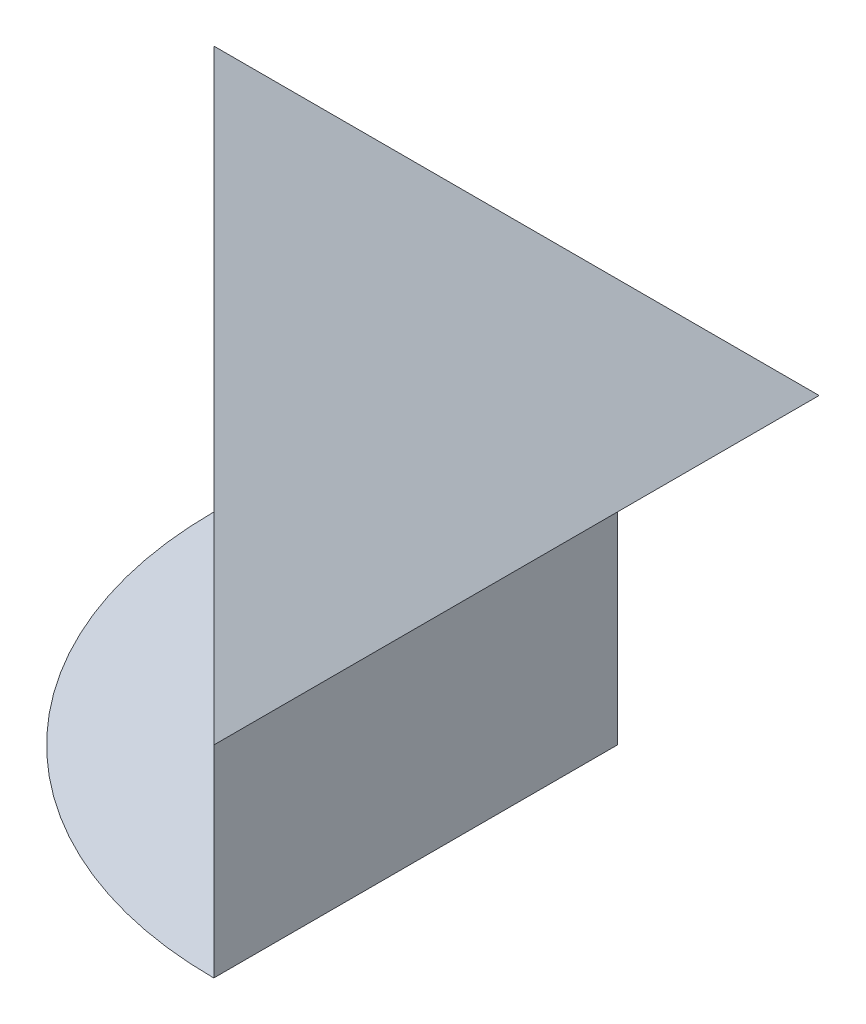
from build123d import *

# Parameters (mm, degrees)
SKETCH1_W           = 40
SKETCH1_H           = 30
BOSS_EXTRUDE2_DEPTH = 60
SKETCH3_W           = 10
SKETCH3_H           = 30
CUT_EXTRUDE1_DEPTH  = 60
CUT_EXTRUDE2_DEPTH  = 60
CUT_EXTRUDE3_DEPTH  = 60
CUT_EXTRUDE4_DEPTH  = 60
BOSS_EXTRUDE7_DEPTH = 0.0001


with BuildPart() as part:
    # Sketch1 → Boss-Extrude2 (new body)
    with BuildSketch(Plane.XY):
        Polygon((50, 30), (20, 60), (-10, 30), (0, 30), (40, 30), align=None)
        with Locations((20, 15)):
            Rectangle(SKETCH1_W, SKETCH1_H)
    extrude(amount=BOSS_EXTRUDE2_DEPTH)

    # Sketch3 → Cut-Extrude1 (cut)
    with BuildSketch(Plane(origin=(0, 0, 0), x_dir=(0, 0, -1), z_dir=(1, 0, 0))):
        Polygon((-30, 60), (0, 60), (0, 30), align=None)
        Polygon((-60, 30), (-60, 60), (-30, 60), align=None)
        with Locations((-5, 15)):
            Rectangle(SKETCH3_W, SKETCH3_H)
        with Locations((-55, 15)):
            Rectangle(SKETCH3_W, SKETCH3_H)
    extrude(amount=CUT_EXTRUDE1_DEPTH, mode=Mode.SUBTRACT)

    # Sketch4 → Cut-Extrude2 (cut)
    with BuildSketch(Plane(origin=(0, 0, 0), x_dir=(0, 0, -1), z_dir=(1, 0, 0))):
        Polygon((-60, 30), (-50, 40), (-60, 40), align=None)
    extrude(amount=-CUT_EXTRUDE2_DEPTH, mode=Mode.SUBTRACT)

    # Sketch5 → Cut-Extrude3 (cut)
    with BuildSketch(Plane(origin=(0, 0, 0), x_dir=(0, 0, -1), z_dir=(1, 0, 0))):
        Polygon((-10, 40), (0, 40), (0, 30), align=None)
    extrude(amount=-CUT_EXTRUDE3_DEPTH, mode=Mode.SUBTRACT)

    # Sketch6 → Cut-Extrude4 (cut)
    with BuildSketch(Plane(origin=(0, 60, 0), x_dir=(1, 0, 0), z_dir=(0, 1, 0))):
        Polygon((-10, 0), (-10, -60), (50, -60), align=None)
    extrude(amount=-CUT_EXTRUDE4_DEPTH, mode=Mode.SUBTRACT)

    # Sketch7 → Boss-Extrude7 (add)
    with BuildSketch(Plane.XZ):
        with BuildLine():
            Line((0, 10), (40, 10))
            Line((40, 10), (40, 50))
            ThreePointArc((40, 50), (11.715728753, 38.284271247), (0, 10))
        make_face()
    extrude(amount=-BOSS_EXTRUDE7_DEPTH)


solid = part.part
